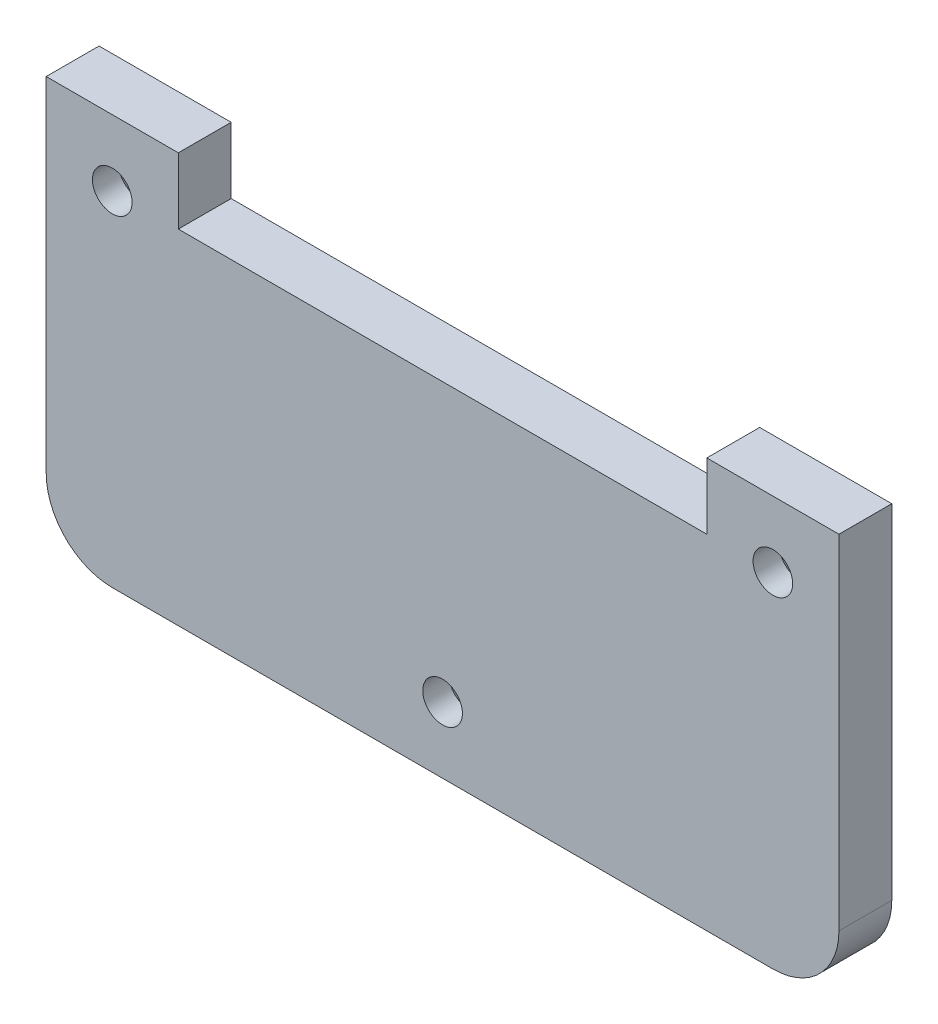
from build123d import *

# Parameters (mm, degrees)
BOSS_EXTRU_1_DEPTH      = 4
ESQUISSE2_R             = 1.5
ENL_V_MAT_EXTRU_1_DEPTH = 4
CHANFREIN1_SIZE         = 2


with BuildPart() as part:
    # Esquisse1 → Boss.-Extru.1 (new body)
    with BuildSketch(Plane.XY):
        with BuildLine():
            Line((10, 0), (0, 0))
            Line((0, 0), (0, -26))
            ThreePointArc((0, -26), (1.464466094, -29.535533906), (5, -31))
            Line((5, -31), (55, -31))
            ThreePointArc((55, -31), (58.535533906, -29.535533906), (60, -26))
            Line((60, -26), (60, 0))
            Line((60, 0), (50, 0))
            Line((50, 0), (50, -5))
            Line((50, -5), (10, -5))
            Line((10, -5), (10, 0))
        make_face()
    extrude(amount=BOSS_EXTRU_1_DEPTH)

    # Esquisse2 → Enlèv. mat.-Extru.1 (cut)
    with BuildSketch(Plane.XY.offset(4)):
        with Locations((30, -26)):
            Circle(ESQUISSE2_R)
        with Locations((5, -5)):
            Circle(ESQUISSE2_R)
        with Locations((55, -5)):
            Circle(ESQUISSE2_R)
    extrude(amount=-ENL_V_MAT_EXTRU_1_DEPTH, mode=Mode.SUBTRACT)

    # Chanfrein1
    chanfrein1_edges = [part.edges().sort_by_distance(p)[0] for p in [
        (28.5, -26, 0),
        (3.5, -5, 0),
        (53.5, -5, 0),
    ]]
    chamfer(chanfrein1_edges, length=CHANFREIN1_SIZE)


solid = part.part
